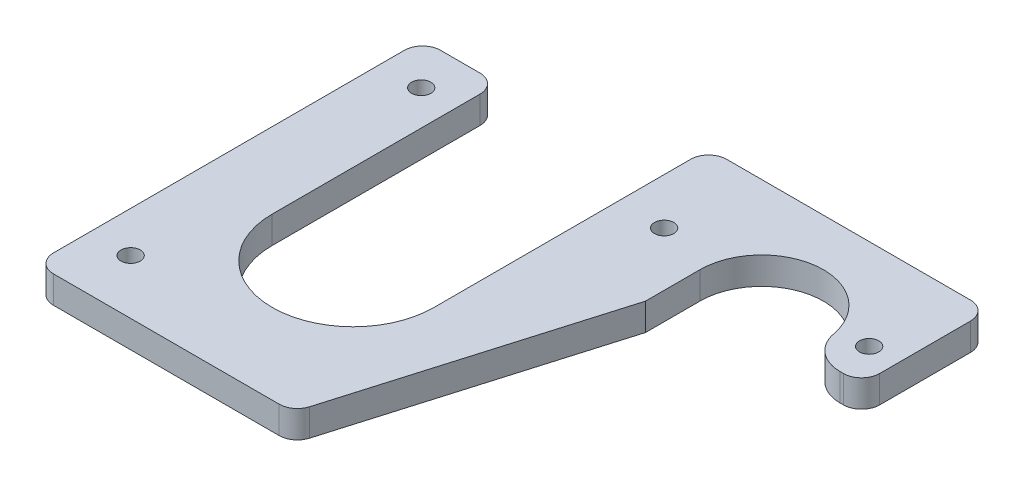
from build123d import *

# Parameters (mm, degrees)
BOSS_EXTRUDE1_DEPTH     = 9.525
SKETCH2_W               = 94.331668948
SKETCH2_H               = 25.4
CUT_EXTRUDE1_DEPTH      = 10.525
FILLET1_R               = 6.35
FILLET2_R               = 6.35
F_1_4_CLEARANCE_HOLE1_D = 6.7564
SKETCH5_W               = 19.685
SKETCH5_H               = 12.7
CUT_EXTRUDE2_DEPTH      = 10.525
FILLET3_R               = 6.35
CUT_EXTRUDE3_DEPTH      = 10.525
FILLET4_R               = 12.7
FILLET5_R               = 6.35


with BuildPart() as part:
    # Sketch1 → Boss-Extrude1 (new body)
    with BuildSketch(Plane(origin=(0, 0, 0), x_dir=(1, 0, 0), z_dir=(0, 1, 0))):
        with BuildLine():
            Line((28.575, 81.75625), (28.575, 160.782))
            Line((28.575, 160.782), (0, 160.782))
            Line((0, 160.782), (0, 0))
            Line((0, 0), (82.55, 0))
            Line((82.55, 0), (118.11, 120.65))
            Line((118.11, 120.65), (118.11, 139.7))
            ThreePointArc((118.11, 139.7), (139.7, 161.29), (161.29, 139.7))
            Line((161.29, 139.7), (161.29, 120.65))
            Line((161.29, 120.65), (180.975, 120.65))
            Line((180.975, 120.65), (180.975, 139.7))
            Line((180.975, 139.7), (180.975, 177.8))
            Line((180.975, 177.8), (121.7041, 177.8))
            Line((121.7041, 177.8), (80.9625, 177.8))
            Line((80.9625, 177.8), (80.9625, 81.75625))
            ThreePointArc((80.9625, 81.75625), (54.76875, 55.5625), (28.575, 81.75625))
        make_face()
    extrude(amount=BOSS_EXTRUDE1_DEPTH)

    # Sketch2 → Cut-Extrude1 (cut, through all)
    with BuildSketch(Plane(origin=(0, 9.525, 0), x_dir=(1, 0, 0), z_dir=(0, 1, 0))):
        with Locations((47.165834474, 12.7)):
            Rectangle(SKETCH2_W, SKETCH2_H)
    extrude(amount=-CUT_EXTRUDE1_DEPTH, mode=Mode.SUBTRACT)

    # Fillet1
    fillet1_edges = [part.edges().sort_by_distance(p)[0] for p in [
        (0, 4.7625, -25.4),
    ]]
    fillet(fillet1_edges, radius=FILLET1_R)

    # Fillet2
    fillet2_edges = [part.edges().sort_by_distance(p)[0] for p in [
        (0, 4.7625, -160.782),
        (180.975, 4.7625, -177.8),
        (180.975, 4.7625, -120.65),
        (90.036315789, 4.7625, -25.4),
    ]]
    fillet(fillet2_edges, radius=FILLET2_R)

    # 1/4 Clearance Hole1 (through all)
    with Locations(Plane(origin=(0, 9.525, 0), x_dir=(1, 0, 0), z_dir=(0, 1, 0))):
        with Locations((14.2875, 146.05), (14.2875, 44.45), (99.2378, 146.05), (170.92295, 146.05)):
            Hole(F_1_4_CLEARANCE_HOLE1_D / 2)

    # Sketch5 → Cut-Extrude2 (cut, through all)
    with BuildSketch(Plane(origin=(0, 9.525, 0), x_dir=(1, 0, 0), z_dir=(0, 1, 0))):
        with Locations((171.1325, 127)):
            Rectangle(SKETCH5_W, SKETCH5_H)
    extrude(amount=-CUT_EXTRUDE2_DEPTH, mode=Mode.SUBTRACT)

    # Fillet3
    fillet3_edges = [part.edges().sort_by_distance(p)[0] for p in [
        (180.975, 4.7625, -133.35),
    ]]
    fillet(fillet3_edges, radius=FILLET3_R)

    # Sketch6 → Cut-Extrude3 (cut, through all)
    with BuildSketch(Plane(origin=(0, 9.525, 0), x_dir=(1, 0, 0), z_dir=(0, 1, 0))):
        with BuildLine():
            Line((26.486121599, 81.75625), (26.486121599, 177.8))
            Line((26.486121599, 177.8), (83.051378401, 177.8))
            Line((83.051378401, 177.8), (83.051378401, 81.75625))
            ThreePointArc((83.051378401, 81.75625), (54.76875, 53.473621599), (26.486121599, 81.75625))
        make_face()
    extrude(amount=-CUT_EXTRUDE3_DEPTH, mode=Mode.SUBTRACT)

    # Fillet4
    fillet4_edges = [part.edges().sort_by_distance(p)[0] for p in [
        (161.29, 4.7625, -133.35),
    ]]
    fillet(fillet4_edges, radius=FILLET4_R)

    # Fillet5
    fillet5_edges = [part.edges().sort_by_distance(p)[0] for p in [
        (26.486121599, 4.7625, -160.782),
        (83.051378401, 4.7625, -177.8),
    ]]
    fillet(fillet5_edges, radius=FILLET5_R)


solid = part.part
